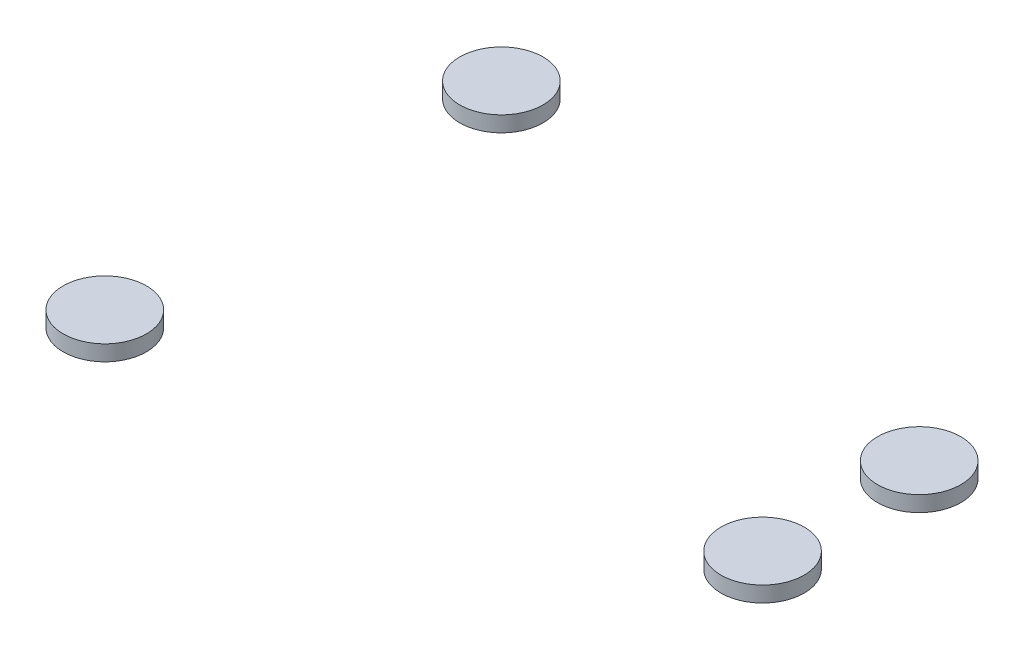
from build123d import *

# Parameters (mm, degrees)
SKETCH1_R             = 4
BOSS_EXTRUDE1_DEPTH   = 1.5
BOSS_EXTRUDE1_2_DEPTH = 1.5
BOSS_EXTRUDE1_3_DEPTH = 1.5
BOSS_EXTRUDE1_4_DEPTH = 1.5


with BuildPart() as part:
    # Sketch1 → Boss-Extrude1 (new body)
    with BuildSketch(Plane(origin=(0, 0, 0), x_dir=(1, 0, 0), z_dir=(0, 1, 0))):
        with Locations((-11, -19.052558883)):
            Circle(SKETCH1_R)
    extrude(amount=-BOSS_EXTRUDE1_DEPTH)


with BuildPart() as body_2:
    # Sketch1 → Boss-Extrude1 2 (new body)
    with BuildSketch(Plane(origin=(0, 0, 0), x_dir=(1, 0, 0), z_dir=(0, 1, 0))):
        with Locations((40.673237657, -7.524443153)):
            Circle(SKETCH1_R)
    extrude(amount=-BOSS_EXTRUDE1_2_DEPTH)


with BuildPart() as body_3:
    # Sketch1 → Boss-Extrude1 3 (new body)
    with BuildSketch(Plane(origin=(0, 0, 0), x_dir=(1, 0, 0), z_dir=(0, 1, 0))):
        with Locations((40.673237657, 7.524443153)):
            Circle(SKETCH1_R)
    extrude(amount=-BOSS_EXTRUDE1_3_DEPTH)


with BuildPart() as body_4:
    # Sketch1 → Boss-Extrude1 4 (new body)
    with BuildSketch(Plane(origin=(0, 0, 0), x_dir=(1, 0, 0), z_dir=(0, 1, 0))):
        with Locations((-11, 19.052558883)):
            Circle(SKETCH1_R)
    extrude(amount=-BOSS_EXTRUDE1_4_DEPTH)


solid = Compound([part.part, body_2.part, body_3.part, body_4.part])
